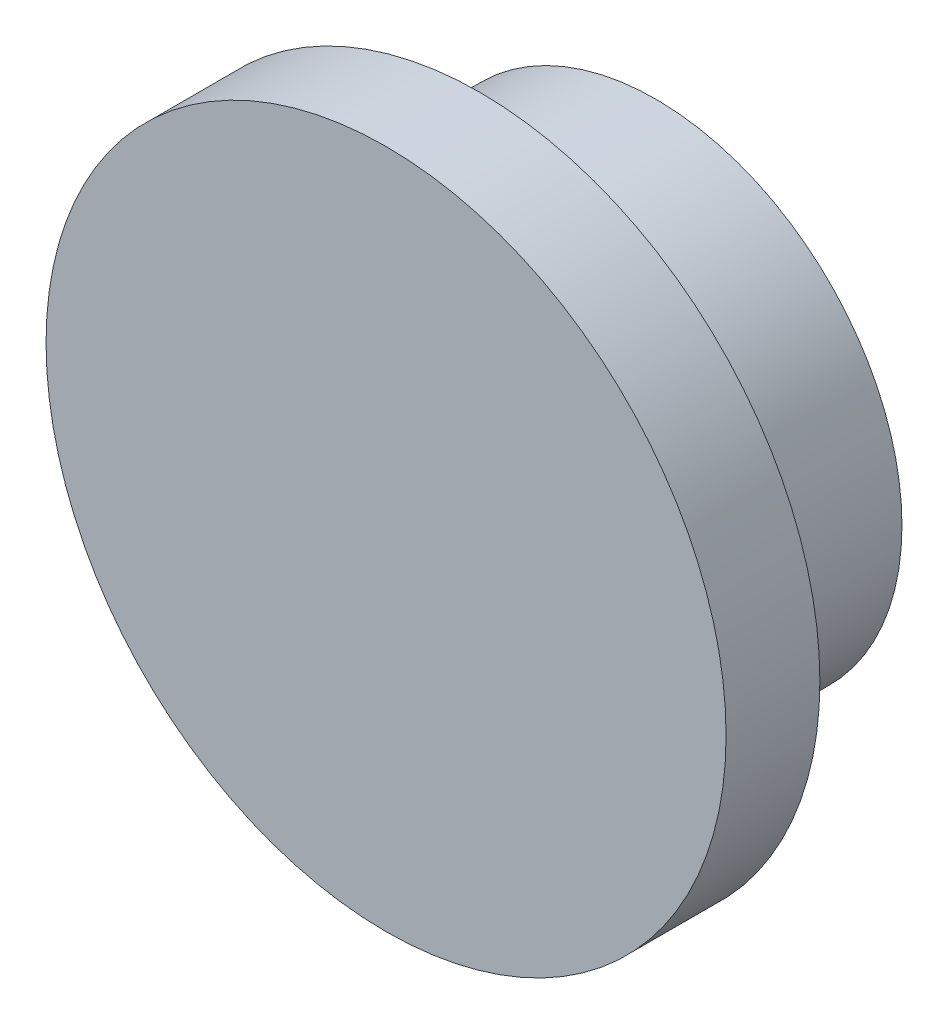
from build123d import *

# Parameters (mm, degrees)
SKETCH1_R           = 9.2075
BOSS_EXTRUDE1_DEPTH = 2.54
SKETCH2_R           = 6.6675
SKETCH2_R_2         = 4.8895
BOSS_EXTRUDE2_DEPTH = 4.7625


with BuildPart() as part:
    # Sketch1 → Boss-Extrude1 (new body)
    with BuildSketch(Plane.XY):
        Circle(SKETCH1_R)
    extrude(amount=BOSS_EXTRUDE1_DEPTH)

    # Sketch2 → Boss-Extrude2 (add)
    with BuildSketch(Plane(origin=(0, 0, 0), x_dir=(-1, 0, 0), z_dir=(0, 0, -1))):
        Circle(SKETCH2_R)
        Circle(SKETCH2_R_2, mode=Mode.SUBTRACT)
    extrude(amount=BOSS_EXTRUDE2_DEPTH)


solid = part.part
